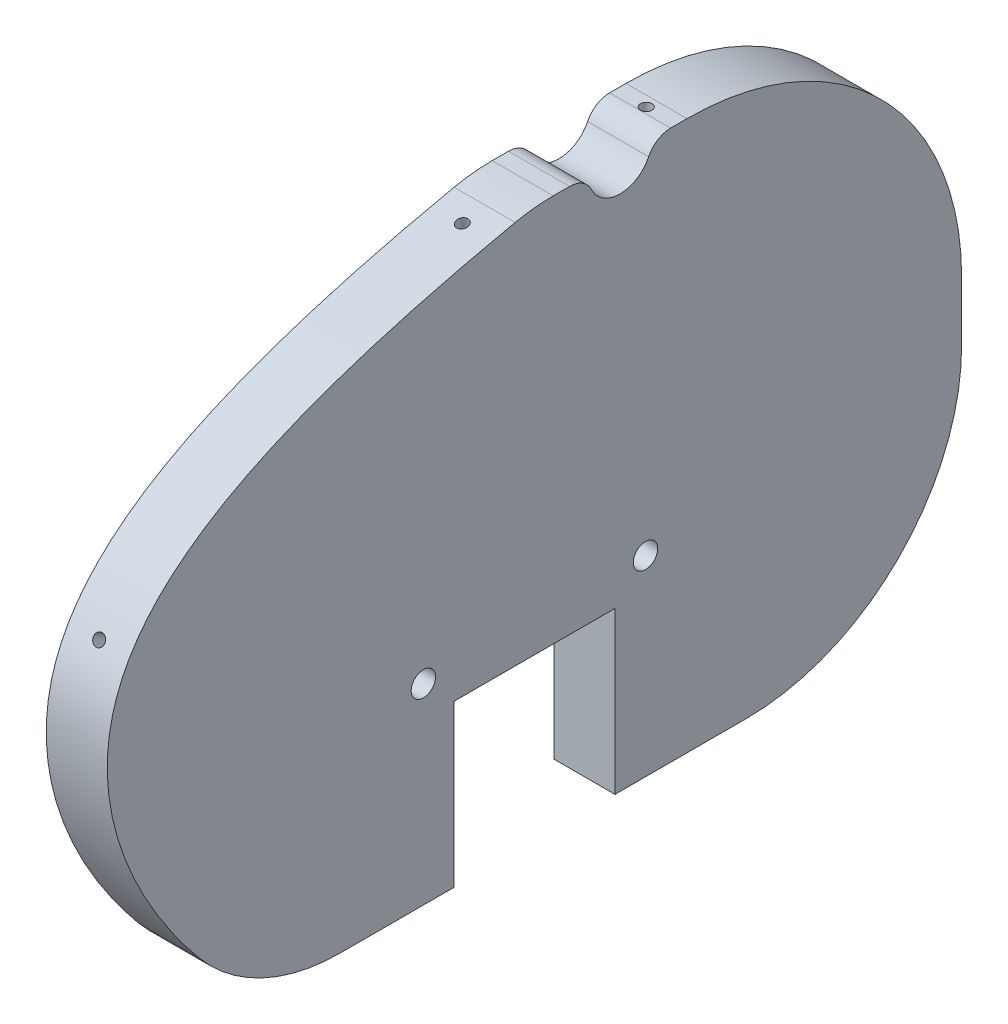
from build123d import *

# Parameters (mm, degrees)
BOSS_EXTRUDE1_DEPTH                  = 3.175
SKETCH2_R                            = 3.302
CUT_EXTRUDE1_DEPTH                   = 7.3500001
FILLET1_R                            = 2.54
SKETCH3_R                            = 1.27
CUT_EXTRUDE2_DEPTH                   = 7.3500001
F_3_64_0_04688_DIAMETER_HOLE4_D      = 1.190752
F_3_64_0_04688_DIAMETER_HOLE4_DEPTH  = 6.35
F_3_64_0_04688_DIAMETER_HOLE4_TIP    = 0.357737992
F_3_64_0_04688_DIAMETER_HOLE5_D      = 1.190752
F_3_64_0_04688_DIAMETER_HOLE5_DEPTH  = 6.35
F_3_64_0_04688_DIAMETER_HOLE5_TIP    = 0.357737992
F_3_64_0_04688_DIAMETER_HOLE8_D      = 1.190752
F_3_64_0_04688_DIAMETER_HOLE8_DEPTH  = 6.35
F_3_64_0_04688_DIAMETER_HOLE8_TIP    = 0.357737992
F_3_64_0_04688_DIAMETER_HOLE10_D     = 1.190752
F_3_64_0_04688_DIAMETER_HOLE10_DEPTH = 6.35
F_3_64_0_04688_DIAMETER_HOLE10_TIP   = 0.357737992
F_3_64_0_04688_DIAMETER_HOLE11_D     = 1.190752
F_3_64_0_04688_DIAMETER_HOLE11_DEPTH = 6.35
F_3_64_0_04688_DIAMETER_HOLE11_TIP   = 0.357737992
F_3_64_0_04688_DIAMETER_HOLE12_D     = 1.190752
F_3_64_0_04688_DIAMETER_HOLE12_DEPTH = 6.35
F_3_64_0_04688_DIAMETER_HOLE12_TIP   = 0.357737992
F_3_64_0_04688_DIAMETER_HOLE13_D     = 1.190752
F_3_64_0_04688_DIAMETER_HOLE13_DEPTH = 6.35
F_3_64_0_04688_DIAMETER_HOLE13_TIP   = 0.357737992
F_3_64_0_04688_DIAMETER_HOLE14_D     = 1.190752
F_3_64_0_04688_DIAMETER_HOLE14_DEPTH = 6.35
F_3_64_0_04688_DIAMETER_HOLE14_TIP   = 0.357737992


with BuildPart() as part:
    # Sketch1 → Boss-Extrude1 (new body, symmetric)
    with BuildSketch(Plane(origin=(0, 0, 0), x_dir=(0, 0, -1), z_dir=(1, 0, 0))):
        with BuildLine():
            ThreePointArc((-2.006494412, 28.159824422), (-0.039619207, 28.470921794), (1.948985172, 28.575))
            Line((1.948985172, 28.575), (15.875, 28.575))
            ThreePointArc((15.875, 28.575), (36.080576272, 20.205576272), (44.45, 0))
            Line((44.45, 0), (44.45, -6.190753211))
            ThreePointArc((44.45, -6.190753211), (37.893805907, -22.018805907), (22.065753211, -28.575))
            Line((22.065753211, -28.575), (8.382, -28.575))
            Line((8.382, -28.575), (8.382, -11.811))
            Line((8.382, -11.811), (-8.382, -11.811))
            Line((-8.382, -11.811), (-8.382, -28.575))
            Line((-8.382, -28.575), (-20.221173657, -28.575))
            ThreePointArc((-20.221173657, -28.575), (-28.345832171, -26.755566561), (-34.918545763, -21.644808297))
            add(Edge.make_bspline(
                [(-2.006494412, 28.159824422), (-30.496101023, 22.112541402), (-51.196498918, 9.980376605), (-41.193293746, -14.035586788), (-34.918545763, -21.644808297)],
                knots=[0.014282519, 0.014282519, 0.014282519, 0.014282519, 0.629767973, 0.915551688, 0.915551688, 0.915551688, 0.915551688], degree=3))
        make_face()
    extrude(amount=BOSS_EXTRUDE1_DEPTH, both=True)

    # Sketch2 → Cut-Extrude1 (cut, through all)
    with BuildSketch(Plane(origin=(3.175, 0, 0), x_dir=(0, 0, -1), z_dir=(1, 0, 0))):
        with Locations((8.911992586, 28.575)):
            Circle(SKETCH2_R)
    extrude(amount=-CUT_EXTRUDE1_DEPTH, mode=Mode.SUBTRACT)

    # Fillet1
    fillet1_edges = [part.edges().sort_by_distance(p)[0] for p in [
        (0, 28.575, -5.609992586),
        (0, 28.575, -12.213992586),
    ]]
    fillet(fillet1_edges, radius=FILLET1_R)

    # Sketch3 → Cut-Extrude2 (cut, through all)
    with BuildSketch(Plane(origin=(3.175, 0, 0), x_dir=(0, 0, -1), z_dir=(1, 0, 0))):
        with Locations((11.557, -8.636)):
            Circle(SKETCH3_R)
        with Locations((-11.557, -8.636)):
            Circle(SKETCH3_R)
    extrude(amount=-CUT_EXTRUDE2_DEPTH, mode=Mode.SUBTRACT)

    # 3/64 (0.04688) Diameter Hole4
    with Locations(Plane(origin=(0, 27.653661398, 4.33381955), x_dir=(0, -0.217552501, 0.97604862), z_dir=(0, 0.97604862, 0.217552501))):
        with Locations((0, 0)):
            Hole(F_3_64_0_04688_DIAMETER_HOLE4_D / 2, depth=F_3_64_0_04688_DIAMETER_HOLE4_DEPTH)
            with Locations((0, 0, -(F_3_64_0_04688_DIAMETER_HOLE4_DEPTH + F_3_64_0_04688_DIAMETER_HOLE4_TIP / 2))):  # 118° drill point
                Cone(0, F_3_64_0_04688_DIAMETER_HOLE4_D / 2, F_3_64_0_04688_DIAMETER_HOLE4_TIP, mode=Mode.SUBTRACT)

    # 3/64 (0.04688) Diameter Hole5
    with Locations(Plane(origin=(0, 28.575, 0), x_dir=(1, 0, 0), z_dir=(0, 1, 0))):
        with Locations((0, 14.807920641)):
            Hole(F_3_64_0_04688_DIAMETER_HOLE5_D / 2, depth=F_3_64_0_04688_DIAMETER_HOLE5_DEPTH)
            with Locations((0, 0, -(F_3_64_0_04688_DIAMETER_HOLE5_DEPTH + F_3_64_0_04688_DIAMETER_HOLE5_TIP / 2))):  # 118° drill point
                Cone(0, F_3_64_0_04688_DIAMETER_HOLE5_D / 2, F_3_64_0_04688_DIAMETER_HOLE5_TIP, mode=Mode.SUBTRACT)

    # 3/64 (0.04688) Diameter Hole8
    with Locations(Plane(origin=(0, 6.972553311, -43.58626351), x_dir=(0, -0.969773001, -0.244008865), z_dir=(0, 0.244008865, -0.969773001))):
        with Locations((0, 0)):
            Hole(F_3_64_0_04688_DIAMETER_HOLE8_D / 2, depth=F_3_64_0_04688_DIAMETER_HOLE8_DEPTH)
            with Locations((0, 0, -(F_3_64_0_04688_DIAMETER_HOLE8_DEPTH + F_3_64_0_04688_DIAMETER_HOLE8_TIP / 2))):  # 118° drill point
                Cone(0, F_3_64_0_04688_DIAMETER_HOLE8_D / 2, F_3_64_0_04688_DIAMETER_HOLE8_TIP, mode=Mode.SUBTRACT)

    # 3/64 (0.04688) Diameter Hole10
    with Locations(Plane(origin=(0, -20.468796932, -39.305009918), x_dir=(0, -0.770151297, 0.637861254), z_dir=(0, -0.637861254, -0.770151297))):
        with Locations((0, 0)):
            Hole(F_3_64_0_04688_DIAMETER_HOLE10_D / 2, depth=F_3_64_0_04688_DIAMETER_HOLE10_DEPTH)
            with Locations((0, 0, -(F_3_64_0_04688_DIAMETER_HOLE10_DEPTH + F_3_64_0_04688_DIAMETER_HOLE10_TIP / 2))):  # 118° drill point
                Cone(0, F_3_64_0_04688_DIAMETER_HOLE10_D / 2, F_3_64_0_04688_DIAMETER_HOLE10_TIP, mode=Mode.SUBTRACT)

    # 3/64 (0.04688) Diameter Hole11
    with Locations(Plane(origin=(0, -28.575, 0), x_dir=(-1, 0, 0), z_dir=(0, -1, 0))):
        with Locations((0, 10.922)):
            Hole(F_3_64_0_04688_DIAMETER_HOLE11_D / 2, depth=F_3_64_0_04688_DIAMETER_HOLE11_DEPTH)
            with Locations((0, 0, -(F_3_64_0_04688_DIAMETER_HOLE11_DEPTH + F_3_64_0_04688_DIAMETER_HOLE11_TIP / 2))):  # 118° drill point
                Cone(0, F_3_64_0_04688_DIAMETER_HOLE11_D / 2, F_3_64_0_04688_DIAMETER_HOLE11_TIP, mode=Mode.SUBTRACT)

    # 3/64 (0.04688) Diameter Hole12
    with Locations(Plane(origin=(0, 9.016155881, 42.122855847), x_dir=(0, 0.862463982, -0.506118444), z_dir=(0, 0.506118444, 0.862463982))):
        with Locations((0, 0)):
            Hole(F_3_64_0_04688_DIAMETER_HOLE12_D / 2, depth=F_3_64_0_04688_DIAMETER_HOLE12_DEPTH)
            with Locations((0, 0, -(F_3_64_0_04688_DIAMETER_HOLE12_DEPTH + F_3_64_0_04688_DIAMETER_HOLE12_TIP / 2))):  # 118° drill point
                Cone(0, F_3_64_0_04688_DIAMETER_HOLE12_D / 2, F_3_64_0_04688_DIAMETER_HOLE12_TIP, mode=Mode.SUBTRACT)

    # 3/64 (0.04688) Diameter Hole13
    with Locations(Plane(origin=(0, -25.802087057, 30.118594378), x_dir=(0, -0.519549644, -0.854440265), z_dir=(0, -0.854440265, 0.519549644))):
        with Locations((1e-09, 0)):
            Hole(F_3_64_0_04688_DIAMETER_HOLE13_D / 2, depth=F_3_64_0_04688_DIAMETER_HOLE13_DEPTH)
            with Locations((0, 0, -(F_3_64_0_04688_DIAMETER_HOLE13_DEPTH + F_3_64_0_04688_DIAMETER_HOLE13_TIP / 2))):  # 118° drill point
                Cone(0, F_3_64_0_04688_DIAMETER_HOLE13_D / 2, F_3_64_0_04688_DIAMETER_HOLE13_TIP, mode=Mode.SUBTRACT)

    # 3/64 (0.04688) Diameter Hole14
    with Locations(Plane(origin=(0, -28.575, 0), x_dir=(-1, 0, 0), z_dir=(0, -1, 0))):
        with Locations((0, -10.922)):
            Hole(F_3_64_0_04688_DIAMETER_HOLE14_D / 2, depth=F_3_64_0_04688_DIAMETER_HOLE14_DEPTH)
            with Locations((0, 0, -(F_3_64_0_04688_DIAMETER_HOLE14_DEPTH + F_3_64_0_04688_DIAMETER_HOLE14_TIP / 2))):  # 118° drill point
                Cone(0, F_3_64_0_04688_DIAMETER_HOLE14_D / 2, F_3_64_0_04688_DIAMETER_HOLE14_TIP, mode=Mode.SUBTRACT)


solid = part.part
